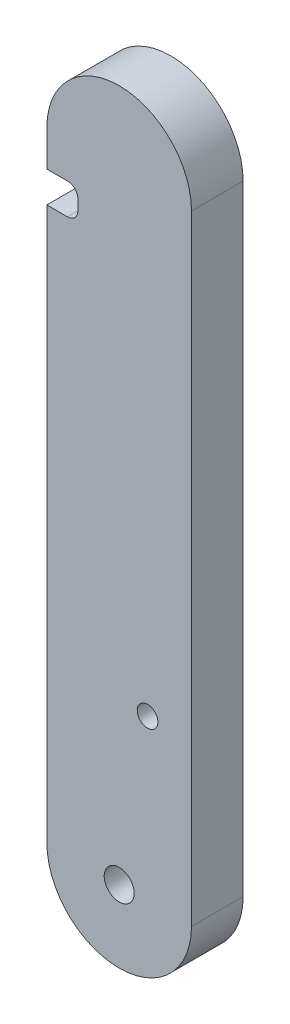
from build123d import *

# Parameters (mm, degrees)
BOSS_EXTRUDE1_DEPTH = 5
SKETCH2_R           = 1
CUT_EXTRUDE1_DEPTH  = 5
SKETCH3_W           = 3
SKETCH3_H           = 3
CUT_EXTRUDE2_DEPTH  = 5
FILLET1_R           = 1
SKETCH4_R           = 1.45
CUT_EXTRUDE3_DEPTH  = 5


with BuildPart() as part:
    # Sketch1 → Boss-Extrude1 (new body)
    with BuildSketch(Plane.XY):
        with BuildLine():
            Line((-22.5, -15.5), (-22.5, 44.5))
            ThreePointArc((-22.5, 44.5), (-15.5, 51.5), (-8.5, 44.5))
            Line((-8.5, 44.5), (-8.5, -15.5))
            ThreePointArc((-8.5, -15.5), (-15.5, -22.5), (-22.5, -15.5))
        make_face()
    extrude(amount=BOSS_EXTRUDE1_DEPTH)

    # Sketch2 → Cut-Extrude1 (cut)
    with BuildSketch(Plane.XY.offset(5)):
        with Locations((-12.75, 0)):
            Circle(SKETCH2_R)
    extrude(amount=-CUT_EXTRUDE1_DEPTH, mode=Mode.SUBTRACT)

    # Sketch3 → Cut-Extrude2 (cut)
    with BuildSketch(Plane.XY.offset(5)):
        with Locations((-21, 39.5)):
            Rectangle(SKETCH3_W, SKETCH3_H)
    extrude(amount=-CUT_EXTRUDE2_DEPTH, mode=Mode.SUBTRACT)

    # Fillet1
    fillet1_edges = [part.edges().sort_by_distance(p)[0] for p in [
        (-19.5, 41, 2.5),
        (-19.5, 38, 2.5),
    ]]
    fillet(fillet1_edges, radius=FILLET1_R)

    # Sketch4 → Cut-Extrude3 (cut)
    with BuildSketch(Plane.XY.offset(5)):
        with Locations((-15.5, -15.5)):
            Circle(SKETCH4_R)
    extrude(amount=-CUT_EXTRUDE3_DEPTH, mode=Mode.SUBTRACT)


solid = part.part
